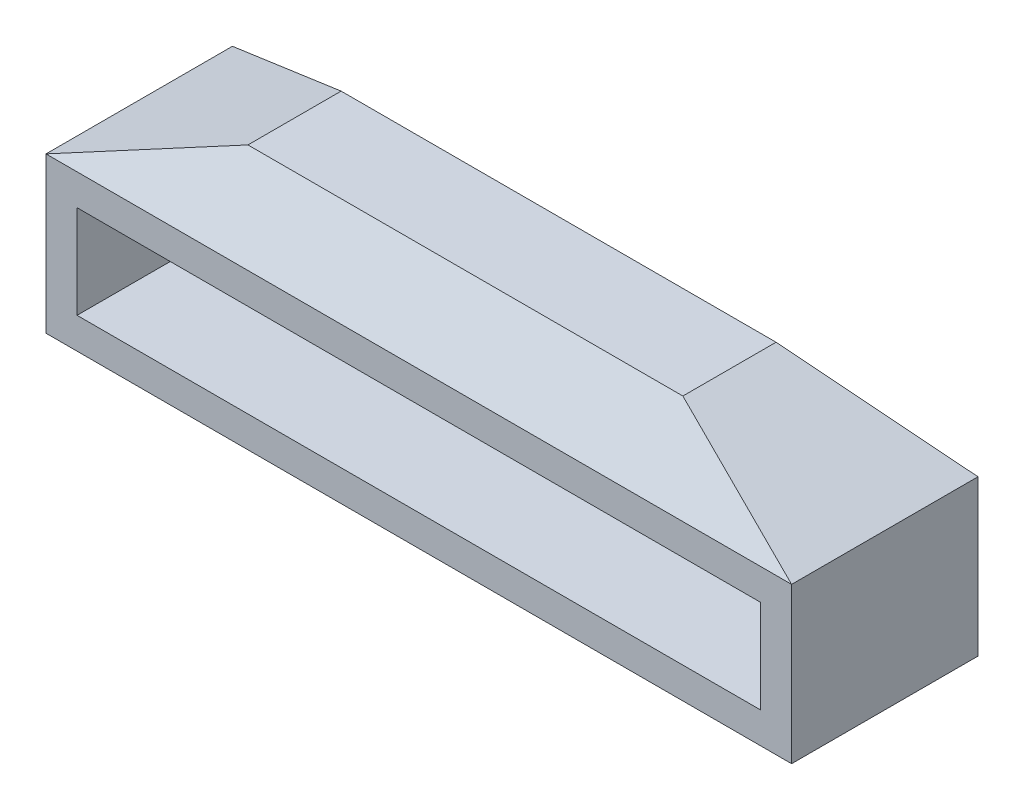
from build123d import *

# Parameters (mm, degrees)
SKETCH1_W           = 24
SKETCH1_H           = 5
SKETCH1_W_2         = 22
SKETCH1_H_2         = 3
BOSS_EXTRUDE1_DEPTH = 6
SKETCH2_W           = 14
SKETCH2_H           = 3
SKETCH5_R           = 1.25
CUT_EXTRUDE1_DEPTH  = 6


with BuildPart() as part:
    # Sketch1 → Boss-Extrude1 (new body)
    with BuildSketch(Plane.XY):
        with Locations((0, 2.5)):
            Rectangle(SKETCH1_W, SKETCH1_H)
        with Locations((0, 2.5)):
            Rectangle(SKETCH1_W_2, SKETCH1_H_2, mode=Mode.SUBTRACT)
    extrude(amount=BOSS_EXTRUDE1_DEPTH)

    # Sketch2 → section 1 of loft1
    with BuildSketch(Plane(origin=(0, 7, 0), x_dir=(1, 0, 0), z_dir=(0, 1, 0)), mode=Mode.PRIVATE) as loft1_s1:
        with Locations((0, -3)):
            Rectangle(SKETCH2_W, SKETCH2_H)
    # loft from a face of the part (loft1)
    loft([part.faces().sort_by_distance((0, 5, 3))[0], loft1_s1.sketch])

    # Sketch5 → Cut-Extrude1 (cut, symmetric)
    with BuildSketch(Plane(origin=(0, 0, 0), x_dir=(0, 0, -1), z_dir=(1, 0, 0))):
        with Locations((-3, 5.224744871)):
            Circle(SKETCH5_R)
    extrude(amount=CUT_EXTRUDE1_DEPTH, both=True, mode=Mode.SUBTRACT)


solid = part.part
